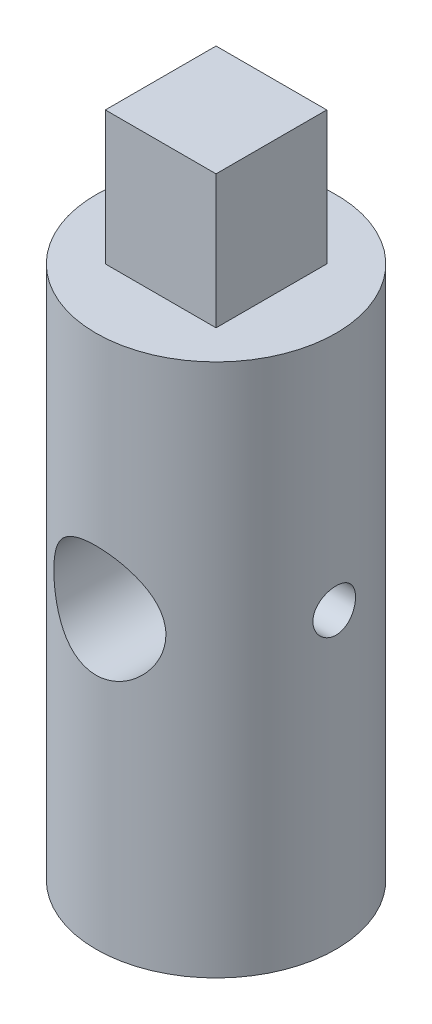
from build123d import *

# Parameters (mm, degrees)
SKETCH_1_R          = 9
EXTRUDE_1_DEPTH     = 40
SKETCH_2_R          = 3.2
CUT_EXTRUDE_1_DEPTH = 17
SKETCH_15_W         = 8.3
SKETCH_15_H         = 8.3
EXTRUDE_2_DEPTH     = 10
SKETCH_16_R         = 4.2
CUT_EXTRUDE_2_DEPTH = 10
SKETCH_17_R         = 1.6
CUT_EXTRUDE_3_DEPTH = 10


with BuildPart() as part:
    # 草图1 → 凸台-拉伸1 (new body)
    with BuildSketch(Plane(origin=(0, 0, 0), x_dir=(1, 0, 0), z_dir=(0, 1, 0))):
        Circle(SKETCH_1_R)
    extrude(amount=EXTRUDE_1_DEPTH)

    # 草图2 → 切除-拉伸1 (cut)
    with BuildSketch(Plane.XZ):
        Circle(SKETCH_2_R)
    extrude(amount=-CUT_EXTRUDE_1_DEPTH, mode=Mode.SUBTRACT)

    # 草图15 → 凸台-拉伸2 (add)
    with BuildSketch(Plane(origin=(0, 40, 0), x_dir=(1, 0, 0), z_dir=(0, 1, 0))):
        Rectangle(SKETCH_15_W, SKETCH_15_H)
    extrude(amount=EXTRUDE_2_DEPTH)

    # 草图16 → 切除-拉伸2 (cut, symmetric)
    with BuildSketch(Plane.XY):
        with Locations((0, 22)):
            Circle(SKETCH_16_R)
    extrude(amount=CUT_EXTRUDE_2_DEPTH, both=True, mode=Mode.SUBTRACT)

    # 草图17 → 切除-拉伸3 (cut, symmetric)
    with BuildSketch(Plane(origin=(0, 0, 0), x_dir=(0, 0, -1), z_dir=(1, 0, 0))):
        with Locations((0, 22)):
            Circle(SKETCH_17_R)
    extrude(amount=CUT_EXTRUDE_3_DEPTH, both=True, mode=Mode.SUBTRACT)


solid = part.part
